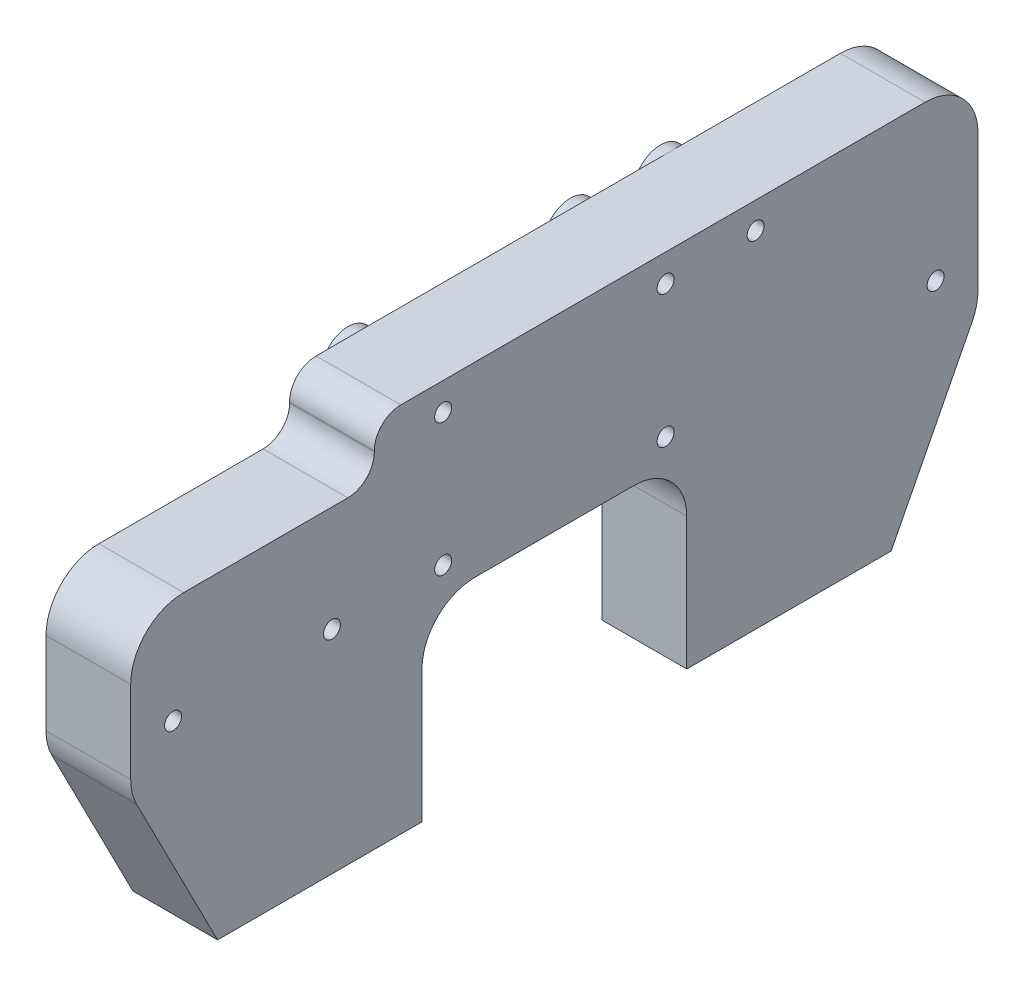
from build123d import *

# Parameters (mm, degrees)
SKETCH2_W             = 80
SKETCH2_H             = 40
BOSS_EXTRUDE1_DEPTH   = 8
SKETCH3_R             = 2.5
BOSS_EXTRUDE2_DEPTH   = 9
SKETCH4_R             = 2.5
BOSS_EXTRUDE3_DEPTH   = 9
SKETCH5_R             = 2.5
BOSS_EXTRUDE4_DEPTH   = 9
CUT_EXTRUDE1_DEPTH    = 58.280013966
FILLET5_R             = 5
FILLET6_R             = 2.5
SKETCH8_W             = 8
SKETCH8_H             = 8
BOSS_EXTRUDE5_DEPTH   = 4
FILLET7_R             = 3.9
M3_CLEARANCE_HOLE1_D  = 3.4
M2X0_4_TAPPED_HOLE1_D = 1.6
FILLET7_OF_MIRROR1_R  = 3.9
SKETCH13_W            = 18.895911776
SKETCH13_H            = 64.667980446
CUT_EXTRUDE2_DEPTH    = 10


with BuildPart() as part:
    # Sketch2 → Boss-Extrude1 (new body)
    with BuildSketch(Plane(origin=(0, 0, 0), x_dir=(0, 0, -1), z_dir=(1, 0, 0))):
        with Locations((0, 20)):
            Rectangle(SKETCH2_W, SKETCH2_H)
    extrude(amount=BOSS_EXTRUDE1_DEPTH)

    # Sketch3 → Boss-Extrude2 (add)
    with BuildSketch(Plane(origin=(8, 0, 0), x_dir=(0, 0, -1), z_dir=(1, 0, 0))):
        with Locations((-36, 20)):
            Circle(SKETCH3_R)
        with Locations((-21, 20)):
            Circle(SKETCH3_R)
    extrude(amount=-BOSS_EXTRUDE2_DEPTH)

    # Sketch4 → Boss-Extrude3 (add)
    with BuildSketch(Plane(origin=(8, 0, 0), x_dir=(0, 0, -1), z_dir=(1, 0, 0))):
        with Locations((19, 32.6)):
            Circle(SKETCH4_R)
        with Locations((36, 20)):
            Circle(SKETCH4_R)
    extrude(amount=-BOSS_EXTRUDE3_DEPTH)

    # Sketch5 → Boss-Extrude4 (add)
    with BuildSketch(Plane(origin=(8, 0, 0), x_dir=(0, 0, -1), z_dir=(1, 0, 0))):
        with Locations((-10.5, 20)):
            Circle(SKETCH5_R)
        with Locations((10.5, 20)):
            Circle(SKETCH5_R)
        with Locations((10.5, 32.5)):
            Circle(SKETCH5_R)
        with Locations((-10.5, 32.5)):
            Circle(SKETCH5_R)
    extrude(amount=-BOSS_EXTRUDE4_DEPTH)

    # Sketch7 → Cut-Extrude1 (cut, through all)
    with BuildSketch(Plane(origin=(8, 0, 0), x_dir=(0, 0, -1), z_dir=(1, 0, 0))):
        Polygon((-31.8, 0), (-40, 16), (-47.08718472, 13.485117516), (-40, -21.908315756), (60.433184959, -20.412978779), (53.645426669, 13.485117516), (40, 16), (31.8, 0), (12.5, 0), (12.5, 17.5), (-12.5, 17.5), (-12.5, 0), align=None)
        Polygon((-40, 30), (-17, 30), (-17, 35.1), (40, 35.1), (58.962780813, 50.466125935), (-17, 44.25101618), (-17, 56.378048051), (-45.880127829, 54.443581987), align=None)
    extrude(amount=-CUT_EXTRUDE1_DEPTH, mode=Mode.SUBTRACT)

    # Fillet5
    fillet5_edges = [part.edges().sort_by_distance(p)[0] for p in [
        (4, 16, -40),
        (4, 35.1, -40),
        (4, 30, 40),
        (4, 16, 40),
        (4, 17.5, -12.5),
        (4, 17.5, 12.5),
    ]]
    fillet(fillet5_edges, radius=FILLET5_R)

    # Fillet6
    fillet6_edges = [part.edges().sort_by_distance(p)[0] for p in [
        (4, 35.1, 17),
        (4, 30, 17),
    ]]
    fillet(fillet6_edges, radius=FILLET6_R)

    # Sketch8 → Boss-Extrude5 (add)
    with BuildSketch(Plane(origin=(0, 0, 0), x_dir=(1, 0, 0), z_dir=(0, 1, 0))):
        with Locations((12, 24)):
            Rectangle(SKETCH8_W, SKETCH8_H)
        with Locations((12, -24)):
            Rectangle(SKETCH8_W, SKETCH8_H)
    boss_extrude5 = extrude(amount=BOSS_EXTRUDE5_DEPTH)

    # Fillet7
    fillet7_edges = [part.edges().sort_by_distance(p)[0] for p in [
        (16, 2, 28),
        (16, 2, 20),
        (16, 2, -20),
        (16, 2, -28),
    ]]
    fillet(fillet7_edges, radius=FILLET7_R)

    # M3 Clearance Hole1 (through all)
    with Locations(Plane(origin=(0, 4, 0), x_dir=(1, 0, 0), z_dir=(0, 1, 0))):
        with Locations((12, -24), (-4, -24), (-4, 24), (12, 24)):
            m3_clearance_hole1 = Hole(M3_CLEARANCE_HOLE1_D / 2)

    # M2x0.4 Tapped Hole1 (through all)
    with Locations(Plane.ZY.offset(1)):
        with Locations((-19, 32.6), (-36, 20), (-10.5, 32.5), (-10.5, 20), (10.5, 20), (10.5, 32.5), (21, 20), (36, 20)):
            Hole(M2X0_4_TAPPED_HOLE1_D / 2)

    # Mirror1: Boss-Extrude5, M3 Clearance Hole1 across plane
    add(boss_extrude5.mirror(Plane(origin=(4, 0, 0), x_dir=(0, 0, 1), z_dir=(1, 0, 0))))
    add(m3_clearance_hole1.mirror(Plane(origin=(4, 0, 0), x_dir=(0, 0, 1), z_dir=(1, 0, 0))), mode=Mode.SUBTRACT)

    # Fillet7 of Mirror1
    fillet7_of_mirror1_edges = [part.edges().sort_by_distance(p)[0] for p in [
        (-8, 2, 28),
        (-8, 2, 20),
        (-8, 2, -20),
        (-8, 2, -28),
    ]]
    fillet(fillet7_of_mirror1_edges, radius=FILLET7_OF_MIRROR1_R)

    # Sketch13 → Cut-Extrude2 (cut)
    with BuildSketch(Plane(origin=(0, 0, 0), x_dir=(1, 0, 0), z_dir=(0, 1, 0))):
        with Locations((17.447955888, 0.533990223)):
            Rectangle(SKETCH13_W, SKETCH13_H)
    extrude(amount=CUT_EXTRUDE2_DEPTH, mode=Mode.SUBTRACT)


solid = part.part
